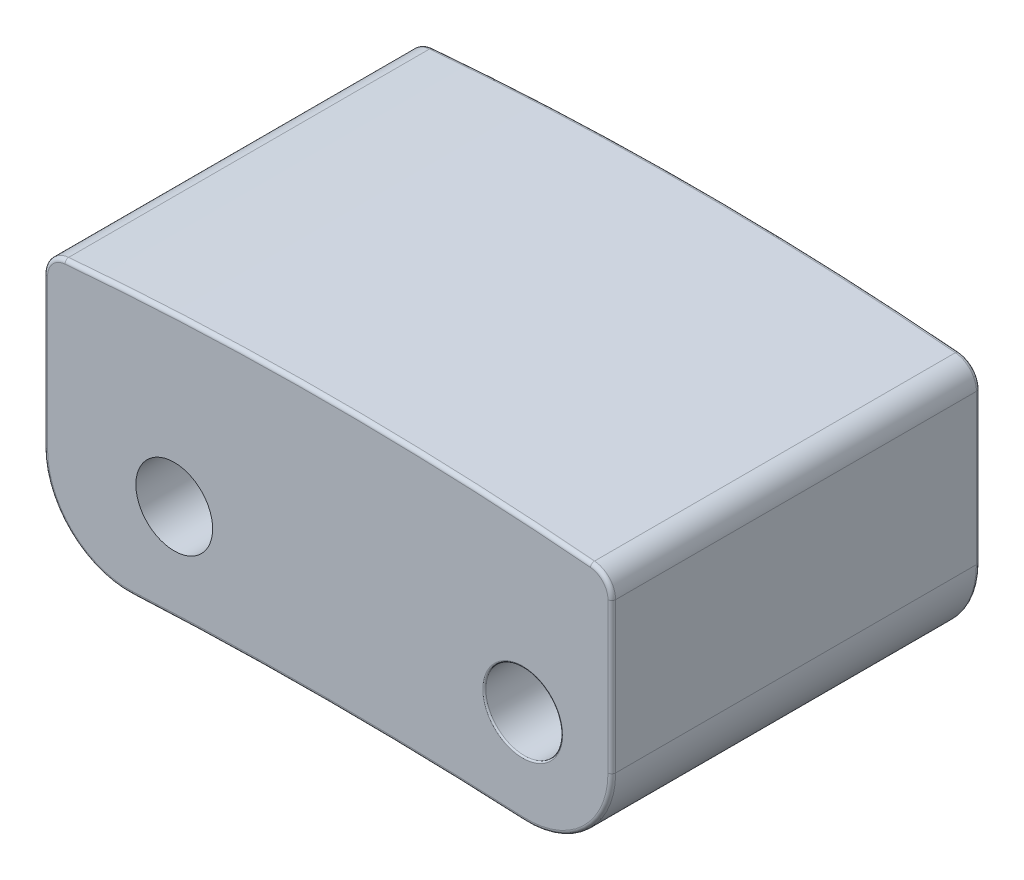
from build123d import *

# Parameters (mm, degrees)
SKETCH1_W               = 7.4
SKETCH1_H               = 3.7
BOSS_EXTRUDE1_DEPTH     = 2.4
CUT_EXTRUDE1_DEPTH      = 4.8
FILLET1_R               = 1.1
FILLET2_R               = 0.3
FILLET3_R               = 0.05
CUT_EXTRUDE2_START      = -1
SKETCH3_R               = 0.5
CUT_EXTRUDE2_DEPTH      = 7.4
FILLET4_R               = 0.02
CUT_EXTRUDE3_START      = -1
SKETCH4_R               = 0.5
CUT_EXTRUDE3_DEPTH      = 4.5
CUT_EXTRUDE4_REACH      = 16.756
CUT_EXTRUDE4_END_RADIUS = 50.4
CUT_EXTRUDE4_START      = -10
SKETCH5_R               = 0.4
FILLET5_R               = 0.05


with BuildPart() as part:
    # Sketch1 → Boss-Extrude1 (new, symmetric)
    with BuildSketch(Plane.XY):
        Rectangle(SKETCH1_W, SKETCH1_H)
    extrude(amount=BOSS_EXTRUDE1_DEPTH, both=True)

    # Sketch2 → Cut-Extrude1 (cut)
    with BuildSketch(Plane.XY.offset(2.4)):
        with BuildLine():
            Line((-3.7, 1.55), (-7.120690005, 4.011417256))
            Line((-7.120690005, 4.011417256), (5.535860742, 3.886722174))
            Line((5.535860742, 3.886722174), (3.7, 1.55))
            ThreePointArc((3.7, 1.55), (0, 1.721492621), (-3.7, 1.55))
        make_face()
        with BuildLine():
            Line((3.7, -1.85), (0.350623614, -3.782025322))
            Line((0.350623614, -3.782025322), (-3.7, -1.85))
            ThreePointArc((-3.7, -1.85), (0, -1.712912069), (3.7, -1.85))
        make_face()
    extrude(amount=-CUT_EXTRUDE1_DEPTH, mode=Mode.SUBTRACT)

    # Fillet1
    fillet1_edges = [part.edges().sort_by_distance(p)[0] for p in [
        (3.7, -1.85, 0),
        (-3.7, -1.85, 0),
    ]]
    fillet(fillet1_edges, radius=FILLET1_R)

    # Fillet2
    fillet2_edges = [part.edges().sort_by_distance(p)[0] for p in [
        (3.7, 1.55, 0),
        (-3.7, 1.55, 0),
    ]]
    fillet(fillet2_edges, radius=FILLET2_R)

    # Fillet3
    fillet3_edges = [part.edges().sort_by_distance(p)[0] for p in [
        (3.7, 0.298266493, -2.4),
        (3.7, 0.298266493, 2.4),
        (0, -1.712912069, -2.4),
        (-3.35777122, -1.476459629, -2.4),
        (3.35777122, -1.476459629, -2.4),
        (0, -1.712912069, 2.4),
        (-3.35777122, -1.476459629, 2.4),
        (3.35777122, -1.476459629, 2.4),
        (0, 1.721492621, 2.4),
        (-3.7, 0.298266493, 2.4),
        (-3.621029193, 1.478477738, 2.4),
        (3.621029193, 1.478477738, 2.4),
        (0, 1.721492621, -2.4),
        (-3.7, 0.298266493, -2.4),
        (-3.621029193, 1.478477738, -2.4),
        (3.621029193, 1.478477738, -2.4),
    ]]
    fillet(fillet3_edges, radius=FILLET3_R)

    # Sketch3 → Cut-Extrude2 (cut, symmetric)
    with BuildSketch(Plane.XY.offset(2.4).offset(CUT_EXTRUDE2_START)):
        with Locations((2.539436079, -0.548443568)):
            Circle(SKETCH3_R)
    extrude(amount=CUT_EXTRUDE2_DEPTH, both=True, mode=Mode.SUBTRACT)

    # Fillet4
    fillet4_edges = [part.edges().sort_by_distance(p)[0] for p in [
        (2.039436079, -0.548443568, 2.4),
        (2.039436079, -0.548443568, -2.4),
    ]]
    fillet(fillet4_edges, radius=FILLET4_R)

    # Sketch4 → Cut-Extrude3 (cut)
    with BuildSketch(Plane(origin=(0, 0, -2.4), x_dir=(-1, 0, 0), z_dir=(0, 0, -1)).offset(CUT_EXTRUDE3_START)):
        with Locations((2, -0.5)):
            Circle(SKETCH4_R)
    extrude(amount=-CUT_EXTRUDE3_DEPTH, mode=Mode.SUBTRACT)

    # Cut-Extrude4: up to this cylinder (the profile starts inside it)
    cut_extrude4_end = Plane(origin=(0, -51.712912069, 1), z_dir=(0, 0, 1)) * Cylinder(CUT_EXTRUDE4_END_RADIUS, 135.312, mode=Mode.PRIVATE)
    # Sketch5 → Cut-Extrude4 (cut, up to the surface)
    with BuildSketch(Plane(origin=(0, 0, 0), x_dir=(1, 0, 0), z_dir=(0, 1, 0)).offset(CUT_EXTRUDE4_START), mode=Mode.PRIVATE) as cut_extrude4_sk1:
        with Locations(Location((0.7, -1, 0), (0, 0, 90))):
            Circle(SKETCH5_R)
    cut_extrude4_tool1 = extrude(cut_extrude4_sk1.sketch, amount=CUT_EXTRUDE4_REACH, mode=Mode.PRIVATE) & cut_extrude4_end
    add(cut_extrude4_tool1.solids().sort_by_distance((0.7, -10, 1))[0], mode=Mode.SUBTRACT)

    # Fillet5
    fillet5_edges = [part.edges().sort_by_distance(p)[0] for p in [
        (0.700029875, -1.717812727, 1.399999999),
    ]]
    fillet(fillet5_edges, radius=FILLET5_R)


solid = part.part
